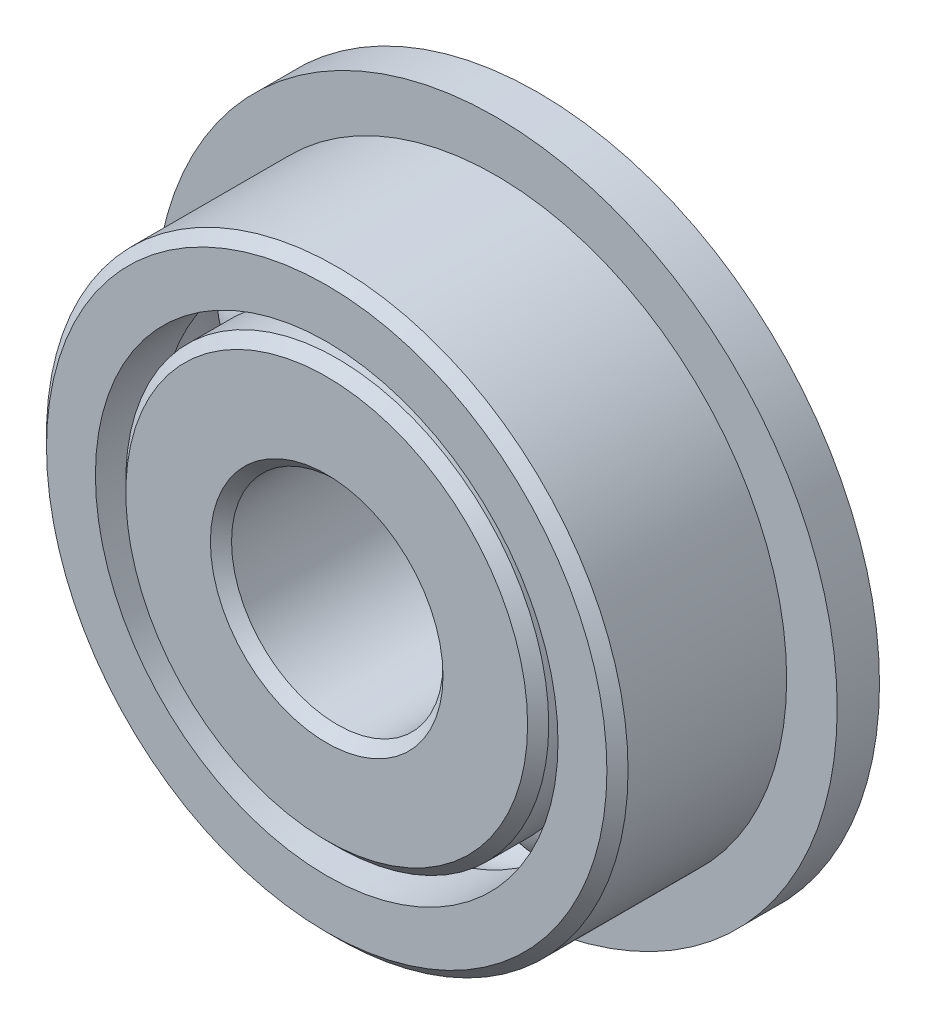
from build123d import *

# Parameters (mm, degrees)
SKETCH6_W         = 1.27
SKETCH6_H         = 3.3035875
CIRPATTERN1_COUNT = 8


with BuildPart() as part:
    # Sketch1 → Revolve1 (revolve)
    with BuildSketch(Plane(origin=(0, 0, 0), x_dir=(0, 0, -1), z_dir=(1, 0, 0))):
        with BuildLine():
            Line((2.8575, 8.73125), (-2.8575, 8.73125))
            Line((-2.8575, 8.73125), (-3.175, 8.41375))
            Line((-3.175, 8.41375), (-3.175, 6.9453125))
            Line((-3.175, 6.9453125), (-1.23924179, 6.9453125))
            ThreePointArc((-1.23924179, 6.9453125), (0, 7.540625), (1.23924179, 6.9453125))
            Line((1.23924179, 6.9453125), (3.175, 6.9453125))
            Line((3.175, 6.9453125), (3.175, 8.41375))
            Line((3.175, 8.41375), (2.8575, 8.73125))
        make_face()
    revolve(axis=Axis((0, 0, 3.175), (0, 0, -1)))

    # Sketch6 → Revolve6 (revolve)
    with BuildSketch(Plane(origin=(0, 0, 0), x_dir=(0, 0, -1), z_dir=(1, 0, 0))):
        with Locations((2.54, 8.59710625)):
            Rectangle(SKETCH6_W, SKETCH6_H)
    revolve(axis=Axis((0, 0, -3.175), (0, 0, 1)))


with BuildPart() as body_2:
    # Sketch3 → Revolve3 (revolve)
    with BuildSketch(Plane(origin=(0, 0, 0), x_dir=(0, 0, -1), z_dir=(1, 0, 0))):
        with BuildLine():
            Line((-3.175, 3.4925), (-3.175, 6.0325))
            Line((-3.175, 6.0325), (-2.8575, 6.35))
            Line((-2.8575, 6.35), (-1.537090266, 6.35))
            ThreePointArc((-1.537090266, 6.35), (0, 4.365625), (1.537090266, 6.35))
            Line((1.537090266, 6.35), (4.4577, 6.35))
            Line((4.4577, 6.35), (4.7752, 6.0325))
            Line((4.7752, 6.0325), (4.7752, 3.4925))
            Line((4.7752, 3.4925), (4.4577, 3.175))
            Line((4.4577, 3.175), (-2.8575, 3.175))
            Line((-2.8575, 3.175), (-3.175, 3.4925))
        make_face()
    revolve(axis=Axis((0, 0, 3.175), (0, 0, -1)))


with BuildPart() as body_3:
    # Sketch4 → Revolve4 (revolve)
    with BuildSketch(Plane(origin=(0, 0, 0), x_dir=(0, 0, -1), z_dir=(1, 0, 0))):
        with BuildLine():
            Line((-1.5875, 5.953125), (1.5875, 5.953125))
            ThreePointArc((1.5875, 5.953125), (0, 7.540625), (-1.5875, 5.953125))
        make_face()
    revolve(axis=Axis((0, 5.953125, 1.5875), (0, 0, -1)))


with BuildPart() as cirpattern1_1:
    # CirPattern1: pattern copy
    add(body_3.part.rotate(Axis((0, 0, 0), (0, 0, 1)), 1 * 360 / CIRPATTERN1_COUNT))


with BuildPart() as cirpattern1_2:
    # CirPattern1: pattern copy
    add(body_3.part.rotate(Axis((0, 0, 0), (0, 0, 1)), 2 * 360 / CIRPATTERN1_COUNT))


with BuildPart() as cirpattern1_3:
    # CirPattern1: pattern copy
    add(body_3.part.rotate(Axis((0, 0, 0), (0, 0, 1)), 3 * 360 / CIRPATTERN1_COUNT))


with BuildPart() as cirpattern1_4:
    # CirPattern1: pattern copy
    add(body_3.part.rotate(Axis((0, 0, 0), (0, 0, 1)), 4 * 360 / CIRPATTERN1_COUNT))


with BuildPart() as cirpattern1_5:
    # CirPattern1: pattern copy
    add(body_3.part.rotate(Axis((0, 0, 0), (0, 0, 1)), 5 * 360 / CIRPATTERN1_COUNT))


with BuildPart() as cirpattern1_6:
    # CirPattern1: pattern copy
    add(body_3.part.rotate(Axis((0, 0, 0), (0, 0, 1)), 6 * 360 / CIRPATTERN1_COUNT))


with BuildPart() as cirpattern1_7:
    # CirPattern1: pattern copy
    add(body_3.part.rotate(Axis((0, 0, 0), (0, 0, 1)), 7 * 360 / CIRPATTERN1_COUNT))


solid = Compound([part.part, body_2.part, body_3.part, cirpattern1_1.part, cirpattern1_2.part, cirpattern1_3.part, cirpattern1_4.part, cirpattern1_5.part, cirpattern1_6.part, cirpattern1_7.part])
